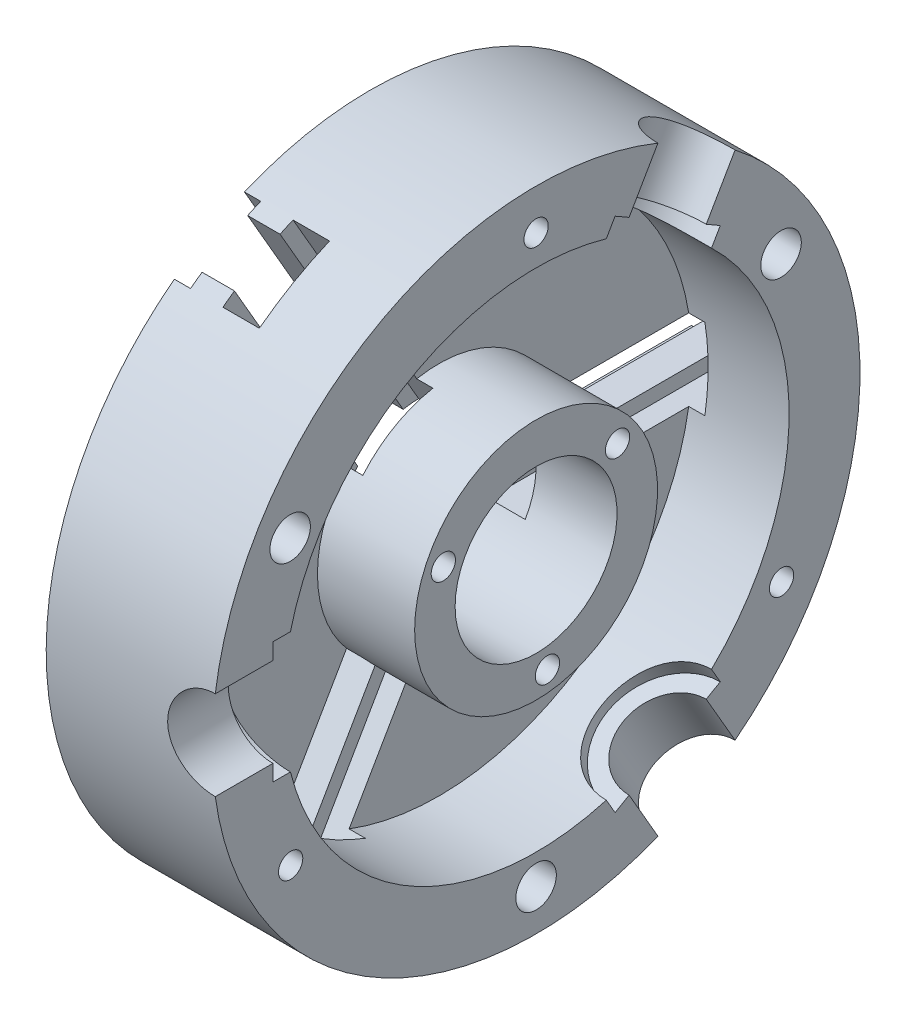
from build123d import *

# Parameters (mm, degrees)
CUT_EXTRUDE1_DEPTH = 81
CIRPATTERN1_COUNT  = 3
CUT_EXTRUDE2_START = -11
SKETCH5_R          = 5
CUT_EXTRUDE2_DEPTH = 30
SKETCH9_R          = 2.999999999
CUT_EXTRUDE3_DEPTH = 41
CIRPATTERN3_COUNT  = 3
SKETCH11_R         = 11
CUT_EXTRUDE4_DEPTH = 15
CUT_EXTRUDE5_START = -4.326695
SKETCH12_R         = 15
CUT_EXTRUDE5_DEPTH = 4.326695
SKETCH15_W         = 10
SKETCH15_H         = 17
CUT_EXTRUDE9_DEPTH = 15
CIRPATTERN5_COUNT  = 3
CIRPATTERN7_COUNT  = 3
CIRPATTERN8_COUNT  = 3


with BuildPart() as part:
    # Sketch1 → Revolve1 (revolve)
    with BuildSketch(Plane.XY):
        Polygon((0, 20), (0, 80), (41, 80), (41, 62.5), (17, 62.5), (17, 30), (41, 30), (41, 20), align=None)
    revolve(axis=Axis((-1000, 0, 0), (1, 0, 0)))

    # Sketch3 → Cut-Extrude1 (cut, through all)
    with BuildSketch(Plane.XY):
        Polygon((0, -10), (0, 10), (4, 10), (4, 6.5), (12, 6.5), (12, 10), (21, 10), (21, -10), (12, -10), (12, -6.5), (4, -6.5), (4, -10), align=None)
    cut_extrude1 = extrude(amount=-CUT_EXTRUDE1_DEPTH, mode=Mode.SUBTRACT)

    # CirPattern1: Cut-Extrude1 ×3 about axis
    cirpattern1_axis = Axis((0, 0, 0), (1, 0, 0))
    for i in range(1, CIRPATTERN1_COUNT):
        add(cut_extrude1.rotate(cirpattern1_axis, i * 360 / CIRPATTERN1_COUNT), mode=Mode.SUBTRACT)

    # Sketch5 → Cut-Extrude2 (cut)
    with BuildSketch(Plane.ZY.offset(CUT_EXTRUDE2_START)):
        with Locations((0, -69.861084208)):
            Circle(SKETCH5_R)
        with Locations((-60.501612866, 35.208201697)):
            Circle(SKETCH5_R)
        with Locations((60.741864319, 35.069492456)):
            Circle(SKETCH5_R)
    extrude(amount=-CUT_EXTRUDE2_DEPTH, mode=Mode.SUBTRACT)

    # Sketch9 → Cut-Extrude3 (cut)
    with BuildSketch(Plane.ZY):
        with Locations((-20.116693275, 14.843134833)):
            Circle(SKETCH9_R)
    cut_extrude3 = extrude(amount=-CUT_EXTRUDE3_DEPTH, mode=Mode.SUBTRACT)

    # CirPattern3: Cut-Extrude3 ×3 about axis
    cirpattern3_axis = Axis((0, 0, 0), (1, 0, 0))
    for i in range(1, CIRPATTERN3_COUNT):
        add(cut_extrude3.rotate(cirpattern3_axis, i * 360 / CIRPATTERN3_COUNT), mode=Mode.SUBTRACT)

    # Sketch11 → Cut-Extrude4 (cut)
    with BuildSketch(Plane.XY.offset(80)):
        with Locations((41, 0)):
            Circle(SKETCH11_R)
    cut_extrude4 = extrude(amount=-CUT_EXTRUDE4_DEPTH, mode=Mode.SUBTRACT)

    # Sketch12 → Cut-Extrude5 (cut)
    with BuildSketch(Plane.XY.offset(65).offset(CUT_EXTRUDE5_START)):
        with Locations((41, 0)):
            Circle(SKETCH12_R)
    cut_extrude5 = extrude(amount=CUT_EXTRUDE5_DEPTH, mode=Mode.SUBTRACT)

    # Sketch15 → Cut-Extrude9 (cut)
    with BuildSketch(Plane(origin=(11, 0, 0), x_dir=(0, 0, -1), z_dir=(1, 0, 0))):
        with Locations((0, -69.861084208)):
            Rectangle(SKETCH15_W, SKETCH15_H)
    cut_extrude9 = extrude(amount=-CUT_EXTRUDE9_DEPTH, mode=Mode.SUBTRACT)

    # CirPattern5: Cut-Extrude9 ×3 about axis
    cirpattern5_axis = Axis((0, 0, 0), (1, 0, 0))
    for i in range(1, CIRPATTERN5_COUNT):
        add(cut_extrude9.rotate(cirpattern5_axis, i * 360 / CIRPATTERN5_COUNT), mode=Mode.SUBTRACT)

    # Sketch19 → Ø6.0mm Dowel Hole3 (revolve, cut)
    with BuildSketch(Plane(origin=(41, 70, 0), x_dir=(0, 0, -1), z_dir=(0, 1, 0))):
        Polygon((0, 0), (0, 31.802581857), (3, 30), (3, 0), align=None)
    f_6_0mm_dowel_hole3 = revolve(axis=Axis((47.35, 70, 0), (-1, 0, 0)), mode=Mode.SUBTRACT)

    # CirPattern7: Ø6.0mm Dowel Hole3 ×3 about axis
    cirpattern7_axis = Axis((0, 0, 0), (1, 0, 0))
    for i in range(1, CIRPATTERN7_COUNT):
        add(f_6_0mm_dowel_hole3.rotate(cirpattern7_axis, i * 360 / CIRPATTERN7_COUNT), mode=Mode.SUBTRACT)

    # CirPattern8: Cut-Extrude4, Cut-Extrude5 ×3 about axis
    cirpattern8_axis = Axis((0, 0, 0), (1, 0, 0))
    for i in range(1, CIRPATTERN8_COUNT):
        add(cut_extrude4.rotate(cirpattern8_axis, i * 360 / CIRPATTERN8_COUNT), mode=Mode.SUBTRACT)
        add(cut_extrude5.rotate(cirpattern8_axis, i * 360 / CIRPATTERN8_COUNT), mode=Mode.SUBTRACT)


solid = part.part
